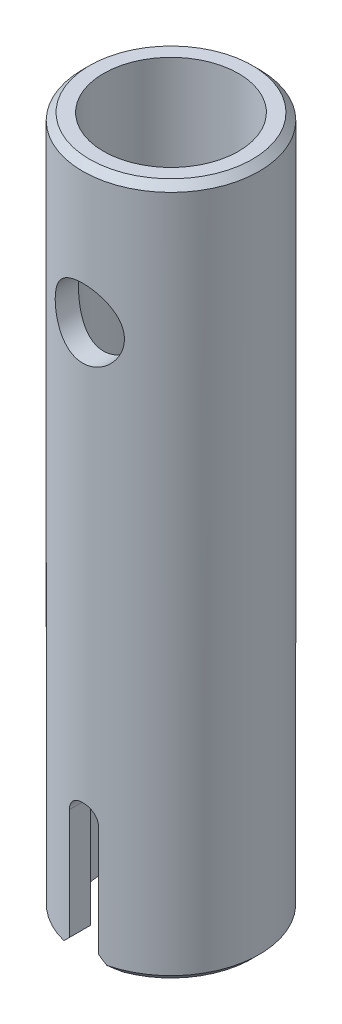
from build123d import *

# Parameters (mm, degrees)
SKETCH1_R           = 6.375
SKETCH1_R_2         = 4.875
BOSS_EXTRUDE1_DEPTH = 50
SKETCH2_W           = 2.1
SKETCH2_H           = 10
CUT_EXTRUDE1_DEPTH  = 52.992337176
CUT_EXTRUDE2_DEPTH  = 52.992337176
FILLET1_R           = 1
CHAMFER1_SIZE       = 0.5
SKETCH4_R           = 2.5
CUT_EXTRUDE3_DEPTH  = 52.992337309


with BuildPart() as part:
    # Sketch1 → Boss-Extrude1 (new body)
    with BuildSketch(Plane(origin=(0, 0, 0), x_dir=(1, 0, 0), z_dir=(0, 1, 0))):
        Circle(SKETCH1_R)
        Circle(SKETCH1_R_2, mode=Mode.SUBTRACT)
    extrude(amount=BOSS_EXTRUDE1_DEPTH)

    # Sketch2 → Cut-Extrude1 (cut, through all)
    with BuildSketch(Plane(origin=(0, 0, -6.375), x_dir=(-1, 0, 0), z_dir=(0, 0, -1))):
        with Locations((0, 5)):
            Rectangle(SKETCH2_W, SKETCH2_H)
    extrude(amount=-CUT_EXTRUDE1_DEPTH, mode=Mode.SUBTRACT)

    # Sketch3 → Cut-Extrude2 (cut, through all)
    with BuildSketch(Plane(origin=(0, 0, -6.375), x_dir=(-1, 0, 0), z_dir=(0, 0, -1))):
        Polygon((2.05, 0), (-2.05, 0), (0, 2.05), align=None)
    extrude(amount=-CUT_EXTRUDE2_DEPTH, mode=Mode.SUBTRACT)

    # Fillet1
    fillet1_edges = [part.edges().sort_by_distance(p)[0] for p in [
        (1.05, 10, 5.524257599),
        (-1.05, 10, 5.524257599),
        (1.05, 10, -5.524257599),
        (-1.05, 10, -5.524257599),
    ]]
    fillet(fillet1_edges, radius=FILLET1_R)

    # Chamfer1
    chamfer1_edges = [part.edges().sort_by_distance(p)[0] for p in [
        (5.182150857, 0, 3.712941893),
        (-6.375, 0, 0),
        (-6.375, 50, 0),
    ]]
    chamfer(chamfer1_edges, length=CHAMFER1_SIZE)

    # Sketch4 → Cut-Extrude3 (cut, through all)
    with BuildSketch(Plane(origin=(0, 0, -6.375), x_dir=(-1, 0, 0), z_dir=(0, 0, -1))):
        with Locations((0, 40)):
            Circle(SKETCH4_R)
    extrude(amount=-CUT_EXTRUDE3_DEPTH, mode=Mode.SUBTRACT)


solid = part.part
